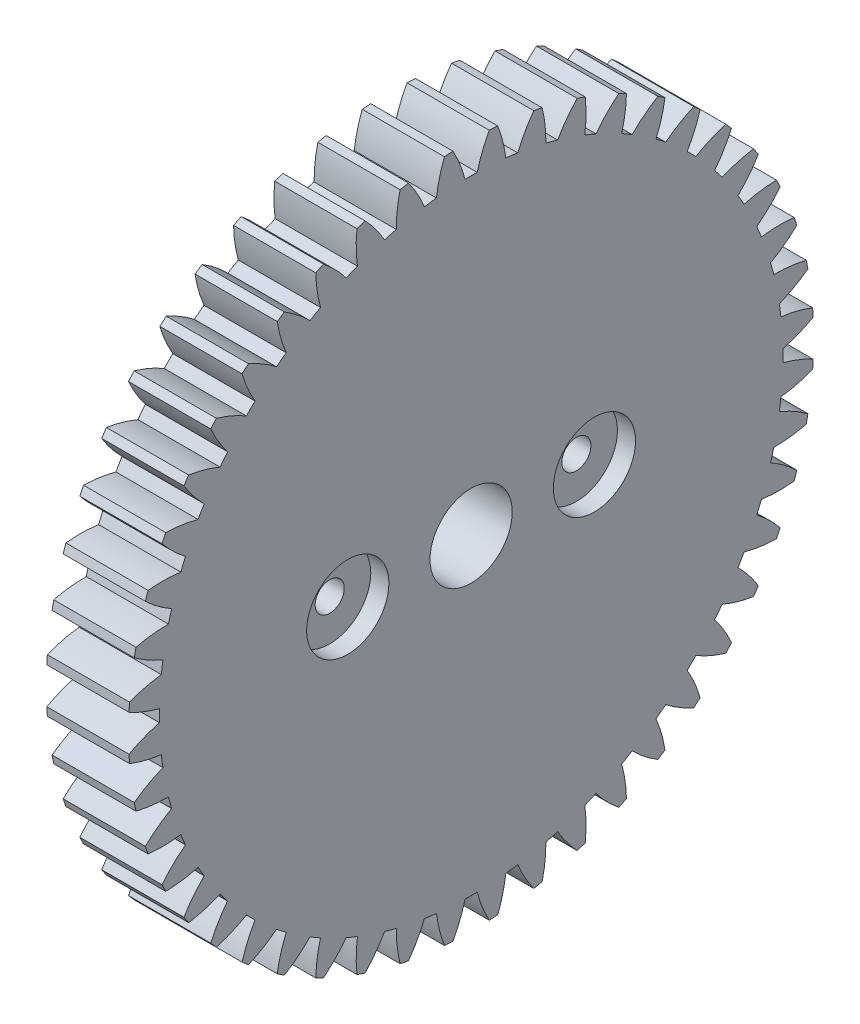
from build123d import *

# Parameters (mm, degrees)
BASPROSKE_W                                = 12.7
BASPROSKE_H                                = 52.916666667
TOOTHCUT_DEPTH                             = 76.905449226
TEETHCUTS_COUNT                            = 48
TEETHCUTS_ANGLE                            = 352.5
BORSKE_R                                   = 6.35
BORE_DEPTH                                 = 50.8000508
CBORE_FOR_8_HEX_MACHINE_SCREW2_D           = 4.4958
CBORE_FOR_8_HEX_MACHINE_SCREW2_CBORE_D     = 12.7
CBORE_FOR_8_HEX_MACHINE_SCREW2_CBORE_DEPTH = 2.794


with BuildPart() as part:
    # BasProSke → Base-Revolve (revolve)
    with BuildSketch(Plane(origin=(0, 0, 0), x_dir=(1, 0, 0), z_dir=(0, 1, 0)), mode=Mode.PRIVATE) as base_revolve_sk:
        with Locations((6.35, 26.458333334)):
            Rectangle(BASPROSKE_W, BASPROSKE_H)
    revolve(base_revolve_sk.sketch.rotate(Axis((-10, 0, 0), (1, 0, 0)), 180), axis=Axis((-10, 0, 0), (1, 0, 0)))

    # TooCutSke → ToothCut (cut, through all)
    with BuildSketch(Plane(origin=(0, 0, 0), x_dir=(0, 0, -1), z_dir=(1, 0, 0))):
        with BuildLine():
            ThreePointArc((0.938681533, 48.143746576), (0, 48.152896667), (-0.938681533, 48.143746576))
            ThreePointArc((-0.938681533, 48.143746576), (-1.729356878, 50.56436869), (-2.816577529, 52.86709103))
            ThreePointArc((-2.816577529, 52.86709103), (0, 52.942066667), (2.816577529, 52.86709103))
            ThreePointArc((2.816577529, 52.86709103), (1.729356878, 50.56436869), (0.938681533, 48.143746576))
        make_face()
    toothcut = extrude(amount=TOOTHCUT_DEPTH, mode=Mode.SUBTRACT)

    # TeethCuts: ToothCut ×48 about axis
    teethcuts_axis = Axis((-10, 0, 0), (1, 0, 0))
    for i in range(1, TEETHCUTS_COUNT):
        add(toothcut.rotate(teethcuts_axis, i * TEETHCUTS_ANGLE / (TEETHCUTS_COUNT - 1)), mode=Mode.SUBTRACT)

    # BorSke → Bore (cut, symmetric)
    with BuildSketch(Plane(origin=(0, 0, 0), x_dir=(0, 0, -1), z_dir=(1, 0, 0))):
        with Locations(Location((0, 0, 0), (0, 0, 180))):
            Circle(BORSKE_R)
    extrude(amount=BORE_DEPTH, both=True, mode=Mode.SUBTRACT)

    # CBORE for #8 Hex Machine Screw2 (through all)
    with Locations(Plane(origin=(12.7, 0, 0), x_dir=(0, 0, -1), z_dir=(1, 0, 0))):
        with Locations((19.05, 0), (-19.05, 0)):
            CounterBoreHole(CBORE_FOR_8_HEX_MACHINE_SCREW2_D / 2, CBORE_FOR_8_HEX_MACHINE_SCREW2_CBORE_D / 2, CBORE_FOR_8_HEX_MACHINE_SCREW2_CBORE_DEPTH)


solid = part.part
